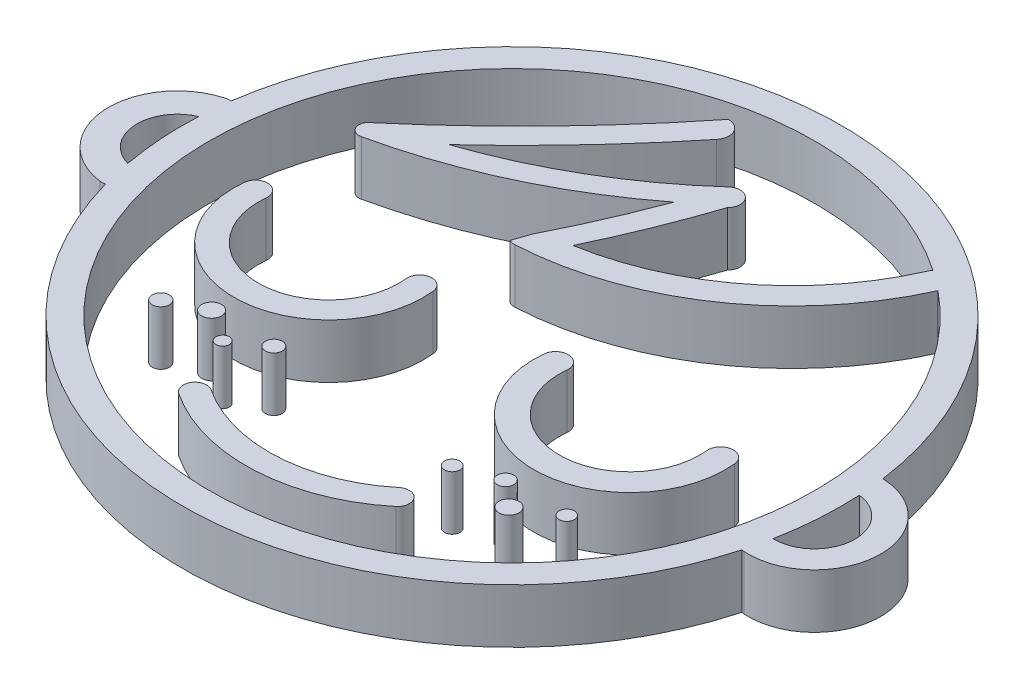
from build123d import *

# Parameters (mm, degrees)
SALIENTE_EXTRUIR1_DEPTH    = 4
SALIENTE_EXTRUIR1_2_DEPTH  = 4
SALIENTE_EXTRUIR1_3_DEPTH  = 4
CROQUIS1_R                 = 0.634147611
SALIENTE_EXTRUIR1_4_DEPTH  = 4
CROQUIS1_R_2               = 0.733396993
SALIENTE_EXTRUIR1_5_DEPTH  = 4
CROQUIS1_R_3               = 0.495614174
SALIENTE_EXTRUIR1_6_DEPTH  = 4
CROQUIS1_R_4               = 0.62551935
SALIENTE_EXTRUIR1_7_DEPTH  = 4
CROQUIS1_R_5               = 0.573021967
SALIENTE_EXTRUIR1_8_DEPTH  = 4
CROQUIS1_R_6               = 0.613581805
SALIENTE_EXTRUIR1_9_DEPTH  = 4
CROQUIS1_R_7               = 0.738734644
SALIENTE_EXTRUIR1_10_DEPTH = 4
CROQUIS1_R_8               = 0.559481515
SALIENTE_EXTRUIR1_11_DEPTH = 4
SALIENTE_EXTRUIR1_12_DEPTH = 4


with BuildPart() as part:
    # Croquis1 → Saliente-Extruir1 (new body)
    with BuildSketch(Plane(origin=(0, 0, 0), x_dir=(1, 0, 0), z_dir=(0, 1, 0))):
        with BuildLine():
            ThreePointArc((74.1799457, 36.466185156), (74.093352849, 36.468100095), (74.006945291, 36.462123248))
            ThreePointArc((74.006945291, 36.462123248), (49.937454193, 57.546084492), (25.778677934, 36.564488912))
            ThreePointArc((25.778677934, 36.564488912), (25.574476045, 36.568511171), (25.373334573, 36.533061235))
            ThreePointArc((25.373334573, 36.533061235), (21.665572097, 31.292911344), (26.04671396, 26.601187839))
            ThreePointArc((26.04671396, 26.601187839), (26.250799676, 26.59321224), (26.452589876, 26.624760696))
            ThreePointArc((26.452589876, 26.624760696), (49.937454193, 8.86639079), (73.346722109, 26.724294626))
            ThreePointArc((73.346722109, 26.724294626), (73.431532152, 26.706709253), (73.517591019, 26.696918434))
            ThreePointArc((73.517591019, 26.696918434), (78.733401721, 31.250374455), (74.1799457, 36.466185156))
        make_face()
        with BuildLine():
            ThreePointArc((25.95430405, 28.766115478), (23.768039797, 31.435458309), (25.573990554, 34.375472662))
            ThreePointArc((25.573990554, 34.375472662), (25.601641514, 31.559776204), (25.95430405, 28.766115478))
        make_face(mode=Mode.SUBTRACT)
        with BuildLine():
            ThreePointArc((74.18816102, 34.557417605), (76.83706478, 31.378945788), (73.783375068, 28.587108873))
            ThreePointArc((73.783375068, 28.587108873), (74.169943046, 31.559776204), (74.18816102, 34.557417605))
        make_face(mode=Mode.SUBTRACT)
        with BuildLine():
            ThreePointArc((48.597651163, 46.457889546), (47.118213116, 42.785490463), (45.425593016, 39.206344036))
            Line((45.425593016, 39.206344036), (44.993103459, 37.95333726))
            ThreePointArc((44.993103459, 37.95333726), (45.217239696, 37.87538969), (45.453858509, 37.857378194))
            ThreePointArc((45.453858509, 37.857378194), (56.509068448, 41.599742996), (64.013179702, 50.539053674))
            ThreePointArc((64.013179702, 50.539053674), (36.494307306, 15.298761068), (62.518026203, 51.657152337))
            ThreePointArc((62.518026203, 51.657152337), (62.466890552, 51.577254722), (62.42425572, 51.492515388))
            ThreePointArc((62.42425572, 51.492515388), (56.485714844, 43.860153446), (47.640867648, 39.950179711))
            ThreePointArc((47.640867648, 39.950179711), (49.408626903, 43.96017081), (50.918352783, 48.074259915))
            ThreePointArc((50.918352783, 48.074259915), (50.948218866, 49.380538478), (49.642890368, 49.43861756))
            ThreePointArc((49.642890368, 49.43861756), (43.508384082, 44.970402926), (36.604580424, 41.818482171))
            ThreePointArc((36.604580424, 41.818482171), (41.569805001, 46.757329696), (46.163596362, 52.043420018))
            ThreePointArc((46.163596362, 52.043420018), (46.291811269, 53.173113113), (45.313276313, 53.7520042))
            ThreePointArc((45.313276313, 53.7520042), (39.105711287, 46.680393607), (32.227179127, 40.259542009))
            ThreePointArc((32.227179127, 40.259542009), (32.106258057, 39.428878951), (32.878756679, 39.10044494))
            ThreePointArc((32.878756679, 39.10044494), (41.148364583, 41.902874928), (48.597651163, 46.457889546))
        make_face(mode=Mode.SUBTRACT)
    extrude(amount=SALIENTE_EXTRUIR1_DEPTH)


with BuildPart() as body_2:
    # Croquis1 → Saliente-Extruir1 2 (new body)
    with BuildSketch(Plane(origin=(0, 0, 0), x_dir=(1, 0, 0), z_dir=(0, 1, 0))):
        with BuildLine():
            ThreePointArc((33.271446194, 31.670423286), (32.467457599, 32.666113812), (31.471767073, 31.862125217))
            ThreePointArc((31.471767073, 31.862125217), (38.438273667, 24.114134575), (45.404780261, 31.862125217))
            ThreePointArc((45.404780261, 31.862125217), (44.409089735, 32.666113812), (43.60510114, 31.670423286))
            ThreePointArc((43.60510114, 31.670423286), (38.438273667, 25.923994948), (33.271446194, 31.670423286))
        make_face()
    extrude(amount=SALIENTE_EXTRUIR1_2_DEPTH)


with BuildPart() as body_3:
    # Croquis1 → Saliente-Extruir1 3 (new body)
    with BuildSketch(Plane(origin=(0, 0, 0), x_dir=(1, 0, 0), z_dir=(0, 1, 0))):
        with BuildLine():
            ThreePointArc((55.381488681, 31.765631263), (54.544027848, 32.796080004), (53.513579106, 31.958619171))
            ThreePointArc((53.513579106, 31.958619171), (60.542287348, 24.166307285), (67.570995591, 31.958619171))
            ThreePointArc((67.570995591, 31.958619171), (66.540546849, 32.796080004), (65.703086016, 31.765631263))
            ThreePointArc((65.703086016, 31.765631263), (60.542287348, 26.044159919), (55.381488681, 31.765631263))
        make_face()
    extrude(amount=SALIENTE_EXTRUIR1_3_DEPTH)


with BuildPart() as body_4:
    # Croquis1 → Saliente-Extruir1 4 (new body)
    with BuildSketch(Plane(origin=(0, 0, 0), x_dir=(1, 0, 0), z_dir=(0, 1, 0))):
        with Locations((35.899204995, 21.257599233)):
            Circle(CROQUIS1_R)
    extrude(amount=SALIENTE_EXTRUIR1_4_DEPTH)


with BuildPart() as body_5:
    # Croquis1 → Saliente-Extruir1 5 (new body)
    with BuildSketch(Plane(origin=(0, 0, 0), x_dir=(1, 0, 0), z_dir=(0, 1, 0))):
        with Locations((38.438273667, 22.469809183)):
            Circle(CROQUIS1_R_2)
    extrude(amount=SALIENTE_EXTRUIR1_5_DEPTH)


with BuildPart() as body_6:
    # Croquis1 → Saliente-Extruir1 6 (new body)
    with BuildSketch(Plane(origin=(0, 0, 0), x_dir=(1, 0, 0), z_dir=(0, 1, 0))):
        with Locations((40.794668254, 20.931235016)):
            Circle(CROQUIS1_R_3)
    extrude(amount=SALIENTE_EXTRUIR1_6_DEPTH)


with BuildPart() as body_7:
    # Croquis1 → Saliente-Extruir1 7 (new body)
    with BuildSketch(Plane(origin=(0, 0, 0), x_dir=(1, 0, 0), z_dir=(0, 1, 0))):
        with Locations((43.032594315, 22.469809183)):
            Circle(CROQUIS1_R_4)
    extrude(amount=SALIENTE_EXTRUIR1_7_DEPTH)


with BuildPart() as body_8:
    # Croquis1 → Saliente-Extruir1 8 (new body)
    with BuildSketch(Plane(origin=(0, 0, 0), x_dir=(1, 0, 0), z_dir=(0, 1, 0))):
        with Locations((57.252749495, 21.42684919)):
            Circle(CROQUIS1_R_5)
    extrude(amount=SALIENTE_EXTRUIR1_8_DEPTH)


with BuildPart() as body_9:
    # Croquis1 → Saliente-Extruir1 9 (new body)
    with BuildSketch(Plane(origin=(0, 0, 0), x_dir=(1, 0, 0), z_dir=(0, 1, 0))):
        with Locations((60.143403991, 22.469809183)):
            Circle(CROQUIS1_R_6)
    extrude(amount=SALIENTE_EXTRUIR1_9_DEPTH)


with BuildPart() as body_10:
    # Croquis1 → Saliente-Extruir1 10 (new body)
    with BuildSketch(Plane(origin=(0, 0, 0), x_dir=(1, 0, 0), z_dir=(0, 1, 0))):
        with Locations((62.008342375, 20.853827223)):
            Circle(CROQUIS1_R_7)
    extrude(amount=SALIENTE_EXTRUIR1_10_DEPTH)


with BuildPart() as body_11:
    # Croquis1 → Saliente-Extruir1 11 (new body)
    with BuildSketch(Plane(origin=(0, 0, 0), x_dir=(1, 0, 0), z_dir=(0, 1, 0))):
        with Locations((64.665879573, 22.469809183)):
            Circle(CROQUIS1_R_8)
    extrude(amount=SALIENTE_EXTRUIR1_11_DEPTH)


with BuildPart() as body_12:
    # Croquis1 → Saliente-Extruir1 12 (new body)
    with BuildSketch(Plane(origin=(0, 0, 0), x_dir=(1, 0, 0), z_dir=(0, 1, 0))):
        with BuildLine():
            ThreePointArc((43.508757823, 17.359730941), (42.314740106, 17.11804024), (42.556430807, 15.924022523))
            ThreePointArc((42.556430807, 15.924022523), (50.311008053, 13.805956585), (57.801408595, 16.723759063))
            ThreePointArc((57.801408595, 16.723759063), (57.916842518, 17.936511186), (56.704090395, 18.051945109))
            ThreePointArc((56.704090395, 18.051945109), (50.220753546, 15.526433126), (43.508757823, 17.359730941))
        make_face()
    extrude(amount=SALIENTE_EXTRUIR1_12_DEPTH)


solid = Compound([part.part, body_2.part, body_3.part, body_4.part, body_5.part, body_6.part, body_7.part, body_8.part, body_9.part, body_10.part, body_11.part, body_12.part])
